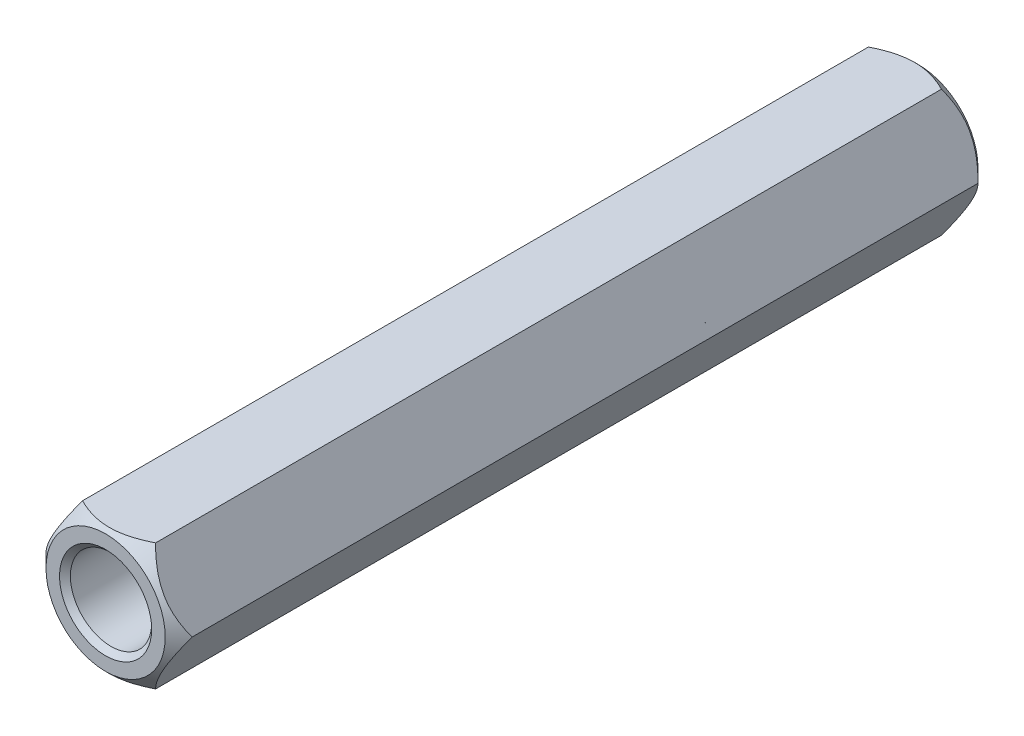
from build123d import *

# Parameters (mm, degrees)
SKETCH_1_R      = 1.5
EXTRUDE_1_DEPTH = 30


with BuildPart() as part:
    # 草图1 → 凸台-拉伸1 (new body)
    with BuildSketch(Plane.XY):
        Polygon((2.696225757, 0), (1.348112879, 2.335), (-1.348112879, 2.335), (-2.696225757, 0), (-1.348112879, -2.335), (1.348112879, -2.335), align=None)
        Circle(SKETCH_1_R, mode=Mode.SUBTRACT)
    extrude(amount=EXTRUDE_1_DEPTH)

    # 切除-扫描1: sweep along a curve in space
    with BuildLine() as sweep_1_path:
        ThreePointArc((1.5, 0, 0), (1.060660172, 1.060660172, 0), (0, 1.5, 0))
        ThreePointArc((0, 1.5, 0), (-1.060660172, 1.060660172, 0), (-1.5, 0, 0))
        ThreePointArc((-1.5, 0, 0), (-1.060660172, -1.060660172, 0), (0, -1.5, 0))
        ThreePointArc((0, -1.5, 0), (1.060660172, -1.060660172, 0), (1.5, 0, 0))
    # 草图2 → 切除-扫描1 (sweep, cut)
    with BuildSketch(Plane(origin=(0, 0, 0), x_dir=(0, 0, -1), z_dir=(1, 0, 0))):
        Polygon((-0.27716486, 1.42283514), (0.101677918, 1.801677918), (0.101677918, 1.42283514), align=None)
        Polygon((0.0715027, 2.1284973), (-0.9284973, 3.1284973), (0.0715027, 3.1284973), align=None)
        Polygon((-29.72283514, 1.42283514), (-30.101677918, 1.801677918), (-30.101677918, 1.42283514), align=None)
        Polygon((-29.0715027, 3.1284973), (-30.0715027, 3.1284973), (-30.0715027, 2.1284973), align=None)
    sweep(path=sweep_1_path.line, mode=Mode.SUBTRACT)


solid = part.part
